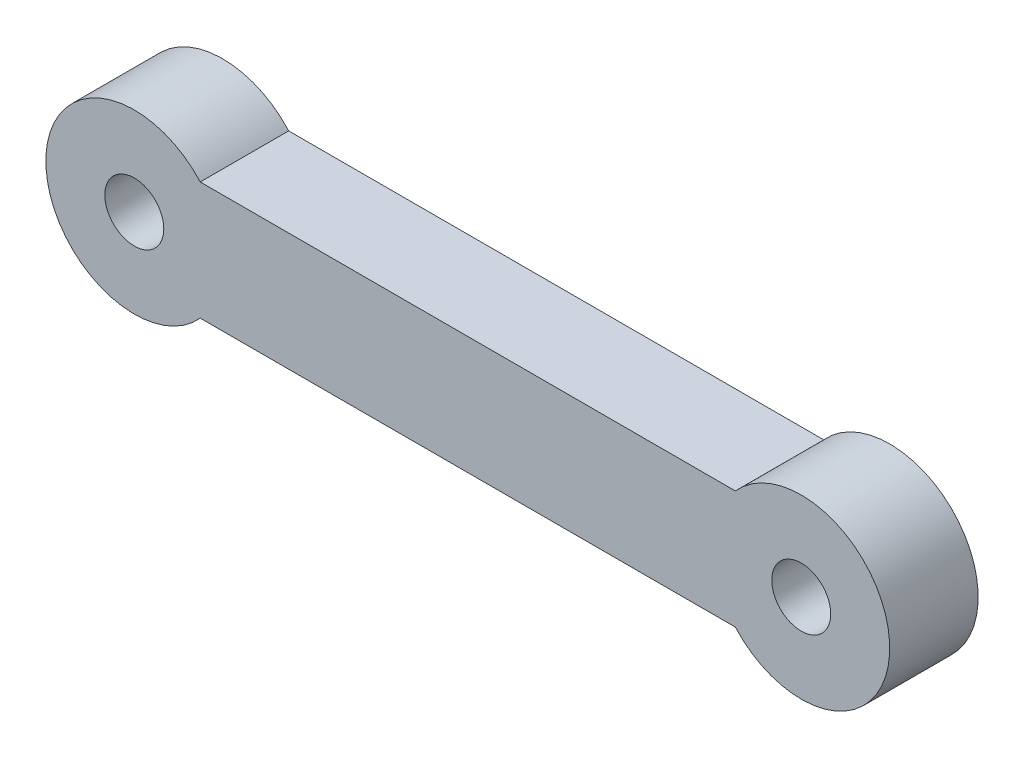
from build123d import *

# Parameters (mm, degrees)
SKETCH1_R           = 1
BOSS_EXTRUDE1_DEPTH = 3


with BuildPart() as part:
    # Sketch1 → Boss-Extrude1 (new body)
    with BuildSketch(Plane.XY):
        with BuildLine():
            Line((-7.673822195, 0.102534963), (10.47404185, 0.102534963))
            ThreePointArc((10.47404185, 0.102534963), (15.710109828, -1.897465037), (10.47404185, -3.897465037))
            Line((10.47404185, -3.897465037), (-7.673822195, -3.897465037))
            ThreePointArc((-7.673822195, -3.897465037), (-12.909890172, -1.897465037), (-7.673822195, 0.102534963))
        make_face()
        with Locations((-9.909890172, -1.897465037)):
            Circle(SKETCH1_R, mode=Mode.SUBTRACT)
        with Locations((12.710109828, -1.897465037)):
            Circle(SKETCH1_R, mode=Mode.SUBTRACT)
    extrude(amount=BOSS_EXTRUDE1_DEPTH)


solid = part.part
